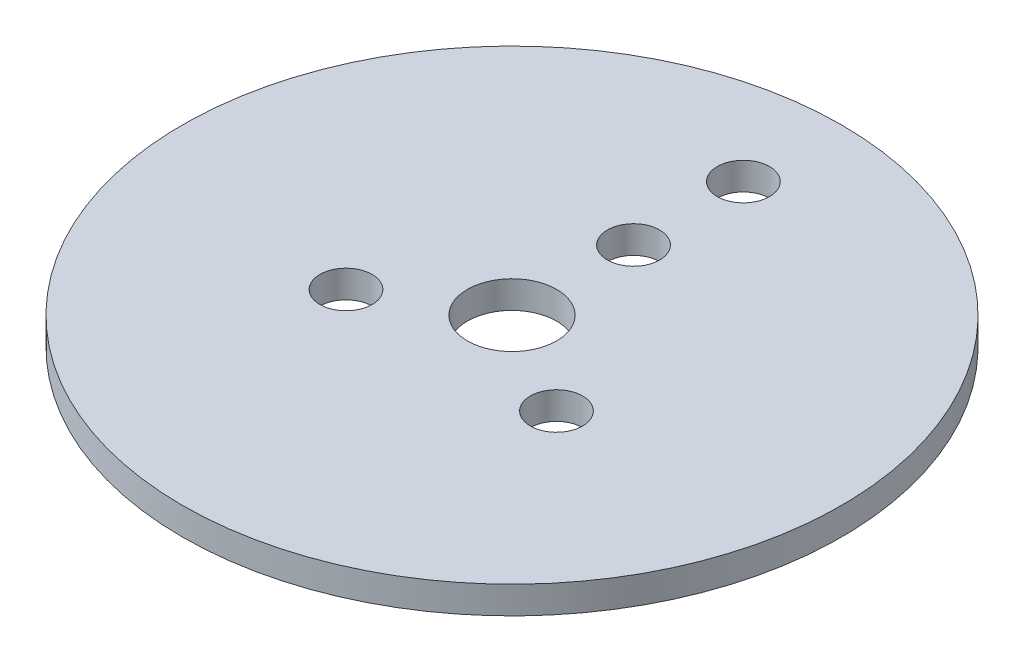
from build123d import *

# Parameters (mm, degrees)
SKETCH1_R           = 24
BOSS_EXTRUDE1_DEPTH = 2
SKETCH2_R           = 3.25
SKETCH2_R_2         = 1.9
CUT_EXTRUDE1_DEPTH  = 3


with BuildPart() as part:
    # Sketch1 → Boss-Extrude1 (new body)
    with BuildSketch(Plane(origin=(0, 0, 0), x_dir=(1, 0, 0), z_dir=(0, 1, 0))):
        Circle(SKETCH1_R)
    extrude(amount=BOSS_EXTRUDE1_DEPTH)

    # Sketch2 → Cut-Extrude1 (cut, through all)
    with BuildSketch(Plane(origin=(0, 2, 0), x_dir=(1, 0, 0), z_dir=(0, 1, 0))):
        Circle(SKETCH2_R)
        with Locations((0, 8.85)):
            Circle(SKETCH2_R_2)
        with Locations((7.664324823, -4.425)):
            Circle(SKETCH2_R_2)
        with Locations((-7.664324823, -4.425)):
            Circle(SKETCH2_R_2)
        with Locations((0, 16.85)):
            Circle(SKETCH2_R_2)
    extrude(amount=-CUT_EXTRUDE1_DEPTH, mode=Mode.SUBTRACT)


solid = part.part
